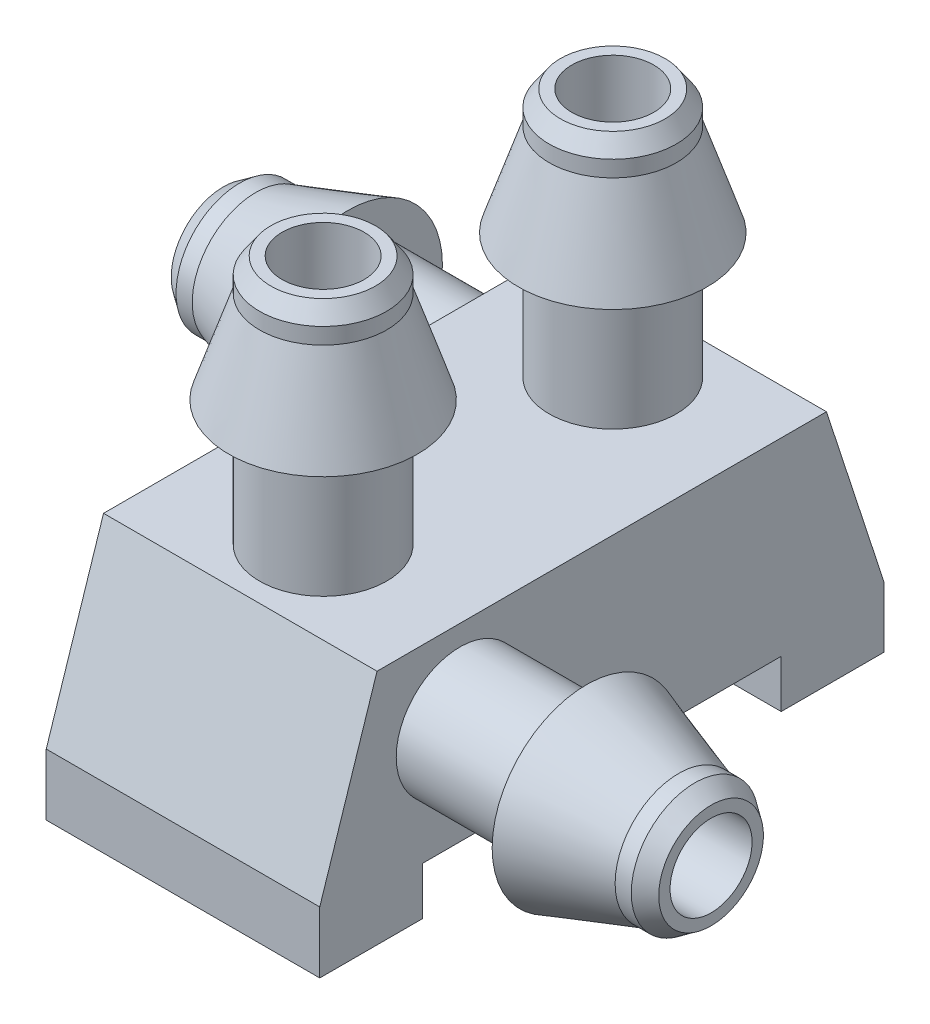
from build123d import *

# Parameters (mm, degrees)
BOSS_EXTRUDE2_DEPTH = 4
SKETCH14_R          = 0.6
CUT_EXTRUDE5_DEPTH  = 2.6
SKETCH15_R          = 0.6
CUT_EXTRUDE6_DEPTH  = 3
SKETCH16_R          = 0.6
CUT_EXTRUDE7_DEPTH  = 2


with BuildPart() as part:
    # Sketch3 → Boss-Extrude2 (new body)
    with BuildSketch(Plane(origin=(0, 0, 0), x_dir=(0, 0, -1), z_dir=(1, 0, 0))):
        Polygon((-19.96095556, -8.537564915), (-14.712271186, -8.537564915), (-14.712271186, -9.237564915), (-13.212271186, -9.237564915), (-13.212271186, -8.337564915), (-14.050172907, -5.770870406), (-20.623053839, -5.770870406), (-21.46095556, -8.337564915), (-21.46095556, -9.237564915), (-19.96095556, -9.237564915), align=None)
    extrude(amount=BOSS_EXTRUDE2_DEPTH)

    # Sketch5 → Revolve2 (revolve)
    with BuildSketch(Plane(origin=(2, 0, 0), x_dir=(0, 0, -1), z_dir=(1, 0, 0))):
        Polygon((-20.341868378, -5.839481614), (-20.011618443, -5.839481614), (-20.011618443, -2.11630703), (-20.17674341, -2.11630703), (-20.341868378, -2.352888512), (-20.341868378, -2.589469995), (-20.790233355, -3.939481614), (-20.341868378, -3.939481614), align=None)
    revolve(axis=Axis((2, -5.639481613, 19.411618443), (0, 1, 0)))

    # Sketch6 → Revolve3 (revolve)
    with BuildSketch(Plane(origin=(2, 0, 0), x_dir=(0, 0, -1), z_dir=(1, 0, 0))):
        Polygon((-16.105788013, -5.839574788), (-15.775538078, -5.839574788), (-15.775538078, -2.116400204), (-15.940663045, -2.116400204), (-16.105788013, -2.352981686), (-16.105788013, -2.589563168), (-16.55415299, -3.939574788), (-16.105788013, -3.939574788), align=None)
    revolve(axis=Axis((2, -6.067987194, 15.175538078), (0, 1, 0)))

    # Sketch12 → Revolve5 (revolve)
    with BuildSketch(Plane(origin=(0, -7, 0), x_dir=(1, 0, 0), z_dir=(0, 1, 0))):
        Polygon((0, -16.075788013), (0, -15.745538078), (-3.723174584, -15.745538078), (-3.723174584, -15.910663045), (-3.486593102, -16.075788013), (-3.250011619, -16.075788013), (-1.9, -16.52415299), (-1.9, -16.075788013), align=None)
    revolve(axis=Axis((0, -7, 15.145538078), (-1, 0, 0)))

    # Sketch13 → Revolve6 (revolve)
    with BuildSketch(Plane(origin=(0, -7, 0), x_dir=(1, 0, 0), z_dir=(0, 1, 0))):
        Polygon((5.851125834, -20.790750246), (7.201137454, -20.342385269), (7.437718936, -20.342385269), (7.674300419, -20.177260302), (7.674300419, -20.012135334), (3.951125834, -20.012135334), (3.951125834, -20.342385269), (5.851125834, -20.342385269), align=None)
    revolve(axis=Axis((3.951125834, -7, 19.412135334), (1, 0, 0)))

    # Sketch14 → Cut-Extrude5 (cut)
    with BuildSketch(Plane.ZY):
        with Locations((15.145538078, -7)):
            Circle(SKETCH14_R)
    extrude(amount=-CUT_EXTRUDE5_DEPTH, mode=Mode.SUBTRACT)

    # Sketch15 → Cut-Extrude6 (cut)
    with BuildSketch(Plane(origin=(4, 0, 0), x_dir=(0, 0, -1), z_dir=(1, 0, 0))):
        with Locations((-19.412135334, -7)):
            Circle(SKETCH15_R)
    extrude(amount=-CUT_EXTRUDE6_DEPTH, mode=Mode.SUBTRACT)

    # Sketch16 → Cut-Extrude7 (cut)
    with BuildSketch(Plane(origin=(0, -5.770870406, 0), x_dir=(1, 0, 0), z_dir=(0, 1, 0))):
        with Locations((2, -15.175538078)):
            Circle(SKETCH16_R)
        with Locations((2, -19.411618443)):
            Circle(SKETCH16_R)
    extrude(amount=-CUT_EXTRUDE7_DEPTH, mode=Mode.SUBTRACT)


solid = part.part
